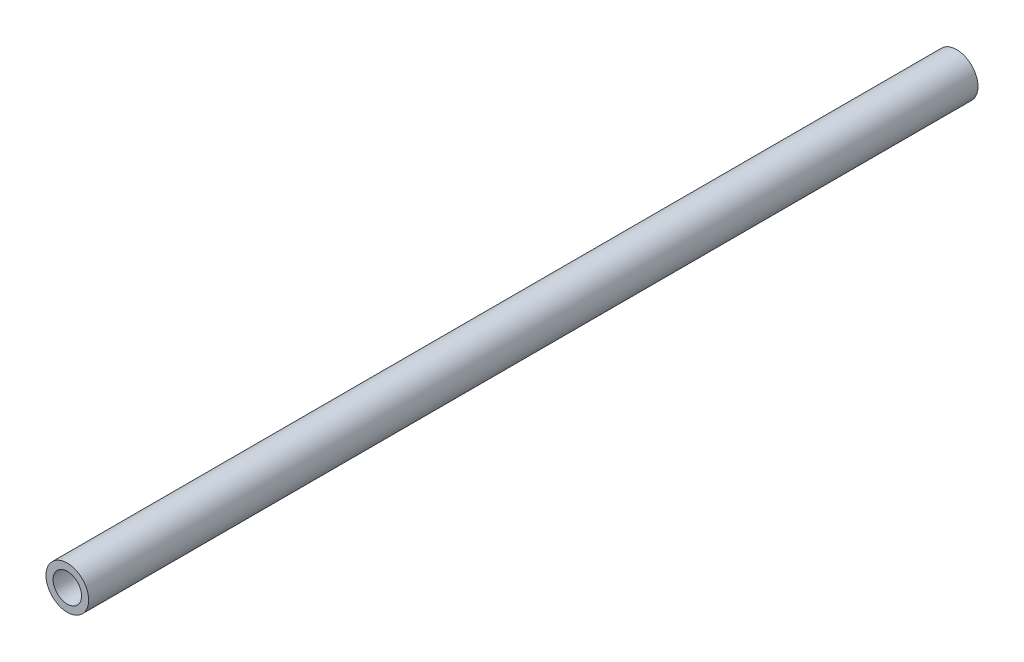
from build123d import *

# Parameters (mm, degrees)
SKETCH1_R           = 3
SKETCH1_R_2         = 2
BOSS_EXTRUDE1_DEPTH = 125


with BuildPart() as part:
    # Sketch1 → Boss-Extrude1 (new body)
    with BuildSketch(Plane.XY):
        Circle(SKETCH1_R)
        Circle(SKETCH1_R_2, mode=Mode.SUBTRACT)
    extrude(amount=BOSS_EXTRUDE1_DEPTH)


solid = part.part
